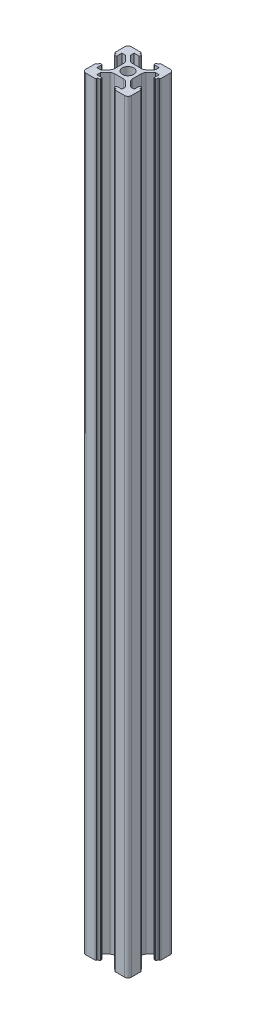
from build123d import *

# Parameters (mm, degrees)
BOSS_EXTRUDE1_DEPTH = 335
FILLET1_R           = 0.35


with BuildPart() as part:
    # Sketch1 → Boss-Extrude1 (new body)
    with BuildSketch(Plane(origin=(0, 0, 0), x_dir=(1, 0, 0), z_dir=(0, 1, 0))):
        with BuildLine():
            Line((3.425126266, 4.485786438), (5.5, 6.560660172))
            Line((5.5, 6.560660172), (5.5, 8.2))
            Line((5.5, 8.2), (3.1, 8.2))
            Line((3.1, 8.2), (3.1, 9.24))
            Line((3.1, 9.24), (4.1, 9.24))
            Line((4.1, 9.24), (4.1, 10))
            Line((4.1, 10), (8.5, 10))
            ThreePointArc((8.5, 10), (9.560660172, 9.560660172), (10, 8.5))
            Line((10, 8.5), (10, 4.1))
            Line((10, 4.1), (9.24, 4.1))
            Line((9.24, 4.1), (9.24, 3.1))
            Line((9.24, 3.1), (8.2, 3.1))
            Line((8.2, 3.1), (8.2, 5.5))
            Line((8.2, 5.5), (6.560660172, 5.5))
            Line((6.560660172, 5.5), (4.485786359, 3.425126187))
            ThreePointArc((4.485786359, 3.425126187), (4.052240856, 2.77627949), (3.899999921, 2.010912625))
            Line((3.899999921, 2.010912625), (3.899999921, 0))
            Line((3.899999921, 0), (3.9, -2.010912703))
            ThreePointArc((3.9, -2.010912703), (4.052240935, -2.776279568), (4.485786438, -3.425126266))
            Line((4.485786438, -3.425126266), (6.560660172, -5.5))
            Line((6.560660172, -5.5), (8.2, -5.5))
            Line((8.2, -5.5), (8.2, -3.1))
            Line((8.2, -3.1), (9.24, -3.1))
            Line((9.24, -3.1), (9.24, -4.1))
            Line((9.24, -4.1), (10, -4.1))
            Line((10, -4.1), (10, -8.5))
            ThreePointArc((10, -8.5), (9.560660172, -9.560660172), (8.5, -10))
            Line((8.5, -10), (4.1, -10))
            Line((4.1, -10), (4.1, -9.24))
            Line((4.1, -9.24), (3.1, -9.24))
            Line((3.1, -9.24), (3.1, -8.2))
            Line((3.1, -8.2), (5.5, -8.2))
            Line((5.5, -8.2), (5.5, -6.560660172))
            Line((5.5, -6.560660172), (3.425126187, -4.485786359))
            ThreePointArc((3.425126187, -4.485786359), (2.77627949, -4.052240856), (2.010912625, -3.899999921))
            Line((2.010912625, -3.899999921), (0, -3.899999921))
            Line((0, -3.899999921), (-2.010912703, -3.9))
            ThreePointArc((-2.010912703, -3.9), (-2.776279568, -4.052240935), (-3.425126266, -4.485786438))
            Line((-3.425126266, -4.485786438), (-5.5, -6.560660172))
            Line((-5.5, -6.560660172), (-5.5, -8.2))
            Line((-5.5, -8.2), (-3.1, -8.2))
            Line((-3.1, -8.2), (-3.1, -9.24))
            Line((-3.1, -9.24), (-4.1, -9.24))
            Line((-4.1, -9.24), (-4.1, -10))
            Line((-4.1, -10), (-8.5, -10))
            ThreePointArc((-8.5, -10), (-9.560660172, -9.560660172), (-10, -8.5))
            Line((-10, -8.5), (-10, -4.1))
            Line((-10, -4.1), (-9.24, -4.1))
            Line((-9.24, -4.1), (-9.24, -3.1))
            Line((-9.24, -3.1), (-8.2, -3.1))
            Line((-8.2, -3.1), (-8.2, -5.5))
            Line((-8.2, -5.5), (-6.560660172, -5.5))
            Line((-6.560660172, -5.5), (-4.485786359, -3.425126187))
            ThreePointArc((-4.485786359, -3.425126187), (-4.052240856, -2.77627949), (-3.899999921, -2.010912625))
            Line((-3.899999921, -2.010912625), (-3.899999921, 0))
            Line((-3.899999921, 0), (-3.9, 2.010912703))
            ThreePointArc((-3.9, 2.010912703), (-4.052240935, 2.776279568), (-4.485786438, 3.425126266))
            Line((-4.485786438, 3.425126266), (-6.560660172, 5.5))
            Line((-6.560660172, 5.5), (-8.2, 5.5))
            Line((-8.2, 5.5), (-8.2, 3.1))
            Line((-8.2, 3.1), (-9.24, 3.1))
            Line((-9.24, 3.1), (-9.24, 4.1))
            Line((-9.24, 4.1), (-10, 4.1))
            Line((-10, 4.1), (-10, 8.5))
            ThreePointArc((-10, 8.5), (-9.560660172, 9.560660172), (-8.5, 10))
            Line((-8.5, 10), (-4.1, 10))
            Line((-4.1, 10), (-4.1, 9.24))
            Line((-4.1, 9.24), (-3.1, 9.24))
            Line((-3.1, 9.24), (-3.1, 8.2))
            Line((-3.1, 8.2), (-5.5, 8.2))
            Line((-5.5, 8.2), (-5.5, 6.560660172))
            Line((-5.5, 6.560660172), (-3.425126187, 4.485786359))
            ThreePointArc((-3.425126187, 4.485786359), (-2.77627949, 4.052240856), (-2.010912625, 3.899999921))
            Line((-2.010912625, 3.899999921), (0, 3.9))
            Line((0, 3.9), (2.010912703, 3.9))
            ThreePointArc((2.010912703, 3.9), (2.776279568, 4.052240935), (3.425126266, 4.485786438))
        make_face()
        with BuildLine():
            ThreePointArc((2.5, 0), (1.767766953, 1.767766953), (0, 2.5))
            ThreePointArc((0, 2.5), (-1.767766953, 1.767766953), (-2.5, 0))
            ThreePointArc((-2.5, 0), (-1.767766953, -1.767766953), (0, -2.5))
            ThreePointArc((0, -2.5), (1.767766953, -1.767766953), (2.5, 0))
        make_face(mode=Mode.SUBTRACT)
    extrude(amount=BOSS_EXTRUDE1_DEPTH)

    # Fillet1
    fillet1_edges = [part.edges().sort_by_distance(p)[0] for p in [
        (5.5, 167.5, -6.560660172),
        (3.1, 167.5, -8.2),
        (3.1, 167.5, -9.24),
        (4.1, 167.5, -9.24),
        (4.1, 167.5, -10),
        (10, 167.5, -4.1),
        (9.24, 167.5, -4.1),
        (9.24, 167.5, -3.1),
        (8.2, 167.5, -3.1),
        (8.2, 167.5, 3.1),
        (9.24, 167.5, 3.1),
        (9.24, 167.5, 4.1),
        (10, 167.5, 4.1),
        (4.1, 167.5, 10),
        (4.1, 167.5, 9.24),
        (3.1, 167.5, 9.24),
        (3.1, 167.5, 8.2),
        (-3.1, 167.5, 8.2),
        (-3.1, 167.5, 9.24),
        (-4.1, 167.5, 9.24),
        (-4.1, 167.5, 10),
        (-10, 167.5, 4.1),
        (-9.24, 167.5, 4.1),
        (-9.24, 167.5, 3.1),
        (-8.2, 167.5, 3.1),
        (-8.2, 167.5, -3.1),
        (-9.24, 167.5, -3.1),
        (-9.24, 167.5, -4.1),
        (-10, 167.5, -4.1),
        (-4.1, 167.5, -10),
        (-4.1, 167.5, -9.24),
        (-3.1, 167.5, -9.24),
        (-3.1, 167.5, -8.2),
    ]]
    fillet(fillet1_edges, radius=FILLET1_R)


solid = part.part
